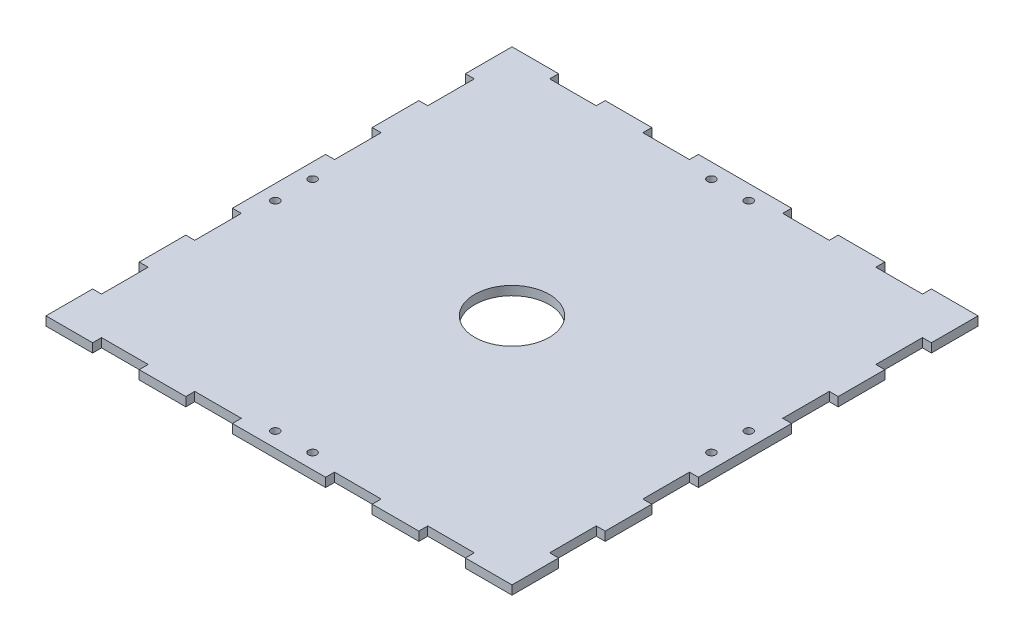
from build123d import *

# Parameters (mm, degrees)
SKETCH1_R           = 12.7
SKETCH1_R_2         = 1.397
BOSS_EXTRUDE1_DEPTH = 3.048


with BuildPart() as part:
    # Sketch1 → Boss-Extrude1 (new body)
    with BuildSketch(Plane(origin=(0, 0, 0), x_dir=(1, 0, 0), z_dir=(0, 1, 0))):
        Polygon((0, 0), (15.875, 0), (15.875, 3.048), (31.75, 3.048), (31.75, 0), (47.625, 0), (47.625, 3.048), (63.5, 3.048), (63.5, 0), (95.25, 0), (95.25, 3.048), (111.125, 3.048), (111.125, 0), (127, 0), (127, 3.048), (142.875, 3.048), (142.875, 0), (158.75, 0), (158.75, 15.875), (155.702, 15.875), (155.702, 31.75), (158.75, 31.75), (158.75, 47.625), (155.702, 47.625), (155.702, 63.5), (158.75, 63.5), (158.75, 95.25), (155.702, 95.25), (155.702, 111.125), (158.75, 111.125), (158.75, 127), (155.702, 127), (155.702, 142.875), (158.75, 142.875), (158.75, 158.75), (142.875, 158.75), (142.875, 155.702), (127, 155.702), (127, 158.75), (111.125, 158.75), (111.125, 155.702), (95.25, 155.702), (95.25, 158.75), (63.5, 158.75), (63.5, 155.702), (47.625, 155.702), (47.625, 158.75), (31.75, 158.75), (31.75, 155.702), (15.875, 155.702), (15.875, 158.75), (0, 158.75), (0, 142.875), (3.048, 142.875), (3.048, 127), (0, 127), (0, 111.125), (3.048, 111.125), (3.048, 95.25), (0, 95.25), (0, 63.5), (3.048, 63.5), (3.048, 47.625), (0, 47.625), (0, 31.75), (3.048, 31.75), (3.048, 15.875), (0, 15.875), align=None)
        with Locations((79.375, 79.375)):
            Circle(SKETCH1_R, mode=Mode.SUBTRACT)
        with Locations((73.025, 153.67)):
            Circle(SKETCH1_R_2, mode=Mode.SUBTRACT)
        with Locations((85.725, 153.67)):
            Circle(SKETCH1_R_2, mode=Mode.SUBTRACT)
        with Locations((153.67, 73.025)):
            Circle(SKETCH1_R_2, mode=Mode.SUBTRACT)
        with Locations((153.67, 85.725)):
            Circle(SKETCH1_R_2, mode=Mode.SUBTRACT)
        with Locations((5.08, 85.725)):
            Circle(SKETCH1_R_2, mode=Mode.SUBTRACT)
        with Locations((5.08, 73.025)):
            Circle(SKETCH1_R_2, mode=Mode.SUBTRACT)
        with Locations((73.025, 5.08)):
            Circle(SKETCH1_R_2, mode=Mode.SUBTRACT)
        with Locations((85.725, 5.08)):
            Circle(SKETCH1_R_2, mode=Mode.SUBTRACT)
    extrude(amount=BOSS_EXTRUDE1_DEPTH)


solid = part.part
